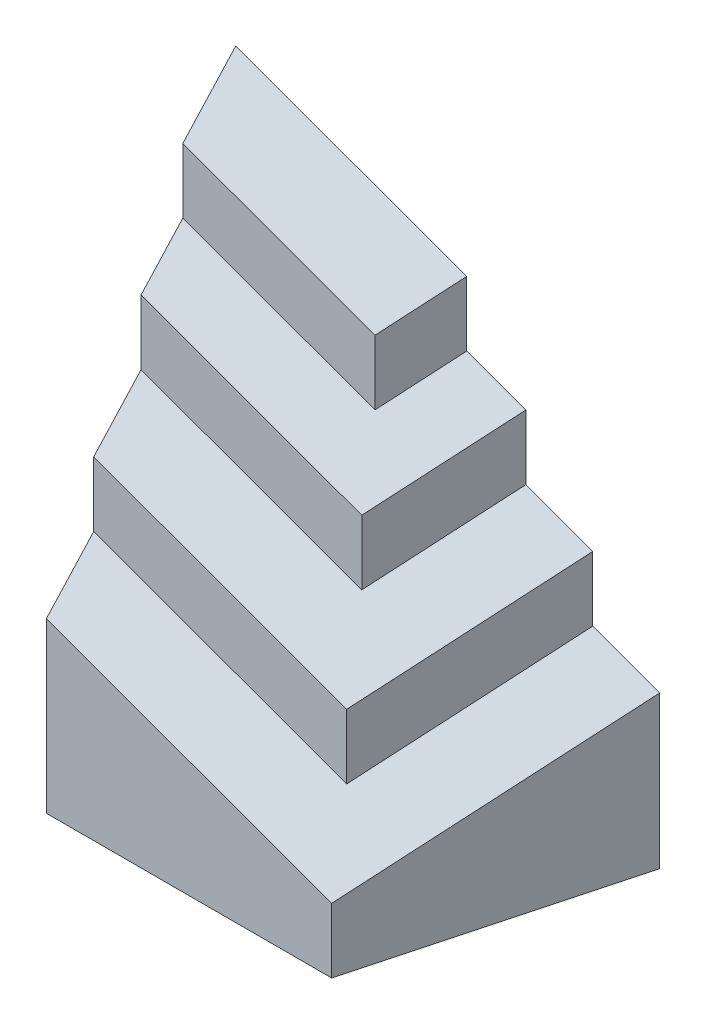
from build123d import *

# Parameters (mm, degrees)
EXTRUDE1_DEPTH     = 90
CUT_EXTRUDE1_DEPTH = 69
SKETCH4_W          = 158.762085971
SKETCH4_H          = 101.139551932
CUT_EXTRUDE2_DEPTH = 30
EXTRUDE2_DEPTH     = 100
CUT_EXTRUDE3_DEPTH = 69
SKETCH8_W          = 142.373577685
SKETCH8_H          = 89.670115664
CUT_EXTRUDE4_DEPTH = 20
EXTRUDE3_DEPTH     = 120
CUT_EXTRUDE5_DEPTH = 69
SKETCH12_W         = 148.763155866
SKETCH12_H         = 89.075175212
CUT_EXTRUDE6_DEPTH = 20
EXTRUDE4_DEPTH     = 140
CUT_EXTRUDE7_DEPTH = 69
SKETCH16_W         = 108.093048797
SKETCH16_H         = 52.640689948
CUT_EXTRUDE8_DEPTH = 10


with BuildPart() as part:
    # Sketch1 → Extrude1 (new body)
    with BuildSketch(Plane(origin=(0, 0, 0), x_dir=(1, 0, 0), z_dir=(0, 1, 0))):
        Polygon((0, 0), (18.220545085, 68), (-93.220545085, 68), (-75, 0), align=None)
    extrude(amount=EXTRUDE1_DEPTH)

    # Sketch2 → Cut-Extrude1 (cut, through all)
    with BuildSketch(Plane(origin=(0, 0, -68), x_dir=(-1, 0, 0), z_dir=(0, 0, -1))):
        Polygon((-18.220545085, 40), (93.220545085, 80.561239696), (93.220545085, 90), (-18.220545085, 90), align=None)
    extrude(amount=-CUT_EXTRUDE1_DEPTH, mode=Mode.SUBTRACT)

    # Sketch4 → Cut-Extrude2 (cut)
    with BuildSketch(Plane(origin=(4.679123258, 12.855785494, 5.602047686), x_dir=(-0.948588376, 0.290160149, 0.126440426), z_dir=(0.316512391, 0.869610646, 0.378942252))):
        with Locations((41.583207075, -49.139243179)):
            Rectangle(SKETCH4_W, SKETCH4_H)
    extrude(amount=CUT_EXTRUDE2_DEPTH, mode=Mode.SUBTRACT)

    # Sketch5 → Extrude2 (add)
    with BuildSketch(Plane(origin=(0, 0, 0), x_dir=(1, 0, 0), z_dir=(0, 1, 0))):
        Polygon((0.620850018, 68), (-13.044558796, 17), (-79.555136271, 17), (-93.220545085, 68), align=None)
    extrude(amount=EXTRUDE2_DEPTH)

    # Sketch6 → Cut-Extrude3 (cut, through all)
    with BuildSketch(Plane(origin=(0, 0, -68), x_dir=(-1, 0, 0), z_dir=(0, 0, -1))):
        Polygon((-0.620850018, 63.405765137), (93.220545085, 97.561239696), (93.220545085, 100), (-0.620850018, 100), align=None)
    extrude(amount=-CUT_EXTRUDE3_DEPTH, mode=Mode.SUBTRACT)

    # Sketch8 → Cut-Extrude4 (cut)
    with BuildSketch(Plane(origin=(9.358246516, 25.711570987, 11.204095371), x_dir=(-0.948588376, 0.290160149, 0.126440426), z_dir=(0.316512391, 0.869610646, 0.378942252))):
        with Locations((46.415862332, -66.070937723)):
            Rectangle(SKETCH8_W, SKETCH8_H)
    extrude(amount=CUT_EXTRUDE4_DEPTH, mode=Mode.SUBTRACT)

    # Sketch9 → Extrude3 (add)
    with BuildSketch(Plane(origin=(0, 0, 0), x_dir=(1, 0, 0), z_dir=(0, 1, 0))):
        Polygon((-16.978845049, 68), (-26.089117591, 34), (-84.110272543, 34), (-93.220545085, 68), align=None)
    extrude(amount=EXTRUDE3_DEPTH)

    # Sketch10 → Cut-Extrude5 (cut, through all)
    with BuildSketch(Plane(origin=(0, 0, -68), x_dir=(-1, 0, 0), z_dir=(0, 0, -1))):
        Polygon((16.978845049, 86.811530273), (93.220545085, 114.561239696), (93.220545085, 120), (16.978845049, 120), align=None)
    extrude(amount=-CUT_EXTRUDE5_DEPTH, mode=Mode.SUBTRACT)

    # Sketch12 → Cut-Extrude6 (cut)
    with BuildSketch(Plane(origin=(14.037369773, 38.567356481, 16.806143057), x_dir=(-0.948588376, 0.290160149, 0.126440426), z_dir=(0.316512391, 0.869610646, 0.378942252))):
        with Locations((45.030500849, -66.338275795)):
            Rectangle(SKETCH12_W, SKETCH12_H)
    extrude(amount=CUT_EXTRUDE6_DEPTH, mode=Mode.SUBTRACT)

    # Sketch13 → Extrude4 (add)
    with BuildSketch(Plane(origin=(0, 0, 0), x_dir=(1, 0, 0), z_dir=(0, 1, 0))):
        Polygon((-93.220545085, 68), (-32.507987755, 68), (-37.599022411, 49), (-88.129510429, 49), align=None)
    extrude(amount=EXTRUDE4_DEPTH)

    # Sketch14 → Cut-Extrude7 (cut, through all)
    with BuildSketch(Plane(origin=(0, 0, -68), x_dir=(-1, 0, 0), z_dir=(0, 0, -1))):
        Polygon((32.507987755, 109.463675982), (93.220545085, 131.561239696), (93.220545085, 140), (32.507987755, 140), align=None)
    extrude(amount=-CUT_EXTRUDE7_DEPTH, mode=Mode.SUBTRACT)

    # Sketch16 → Cut-Extrude8 (cut)
    with BuildSketch(Plane(origin=(18.716493031, 51.423141974, 22.408190743), x_dir=(-0.948588376, 0.290160149, 0.126440426), z_dir=(0.316512391, 0.869610646, 0.378942252))):
        with Locations((79.37385231, -93.938274555)):
            Rectangle(SKETCH16_W, SKETCH16_H)
    extrude(amount=CUT_EXTRUDE8_DEPTH, mode=Mode.SUBTRACT)


solid = part.part
